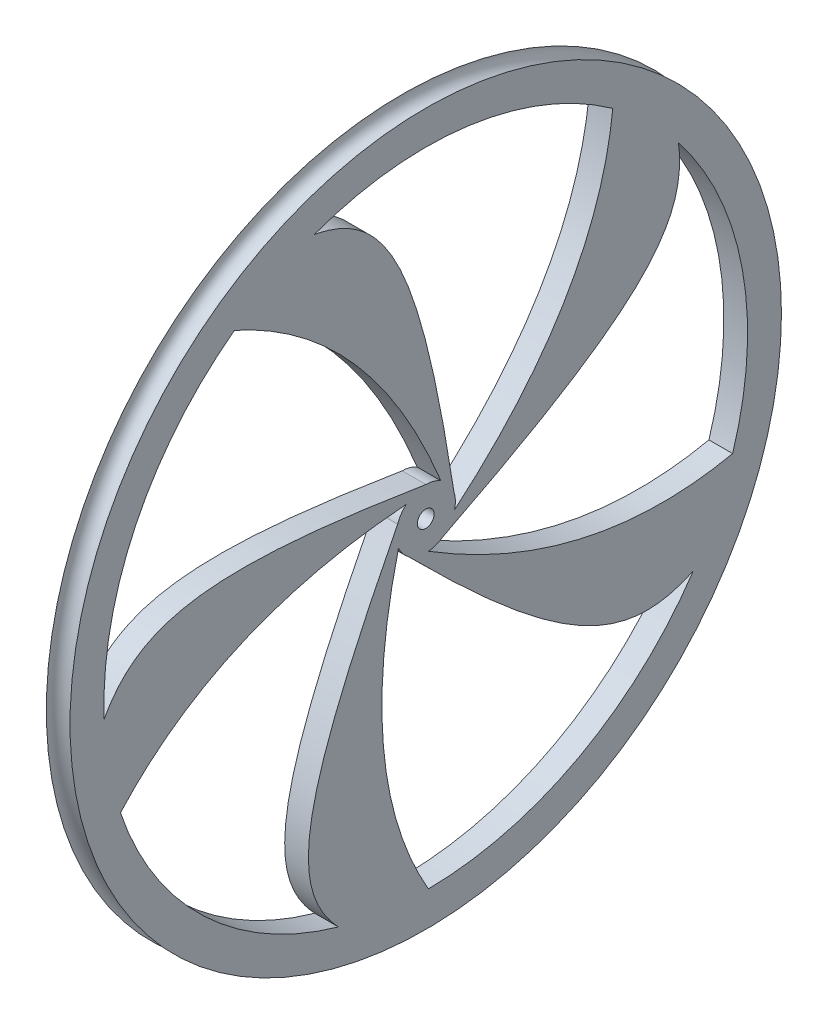
from build123d import *

# Parameters (mm, degrees)
SKETCH3_R           = 4.445
SKETCH3_R_2         = 1.2573
BOSS_EXTRUDE1_DEPTH = 1.778
BOSS_EXTRUDE2_DEPTH = 1.778
CIRPATTERN1_COUNT   = 5


with BuildPart() as part:
    # Sketch1 → Revolve1 (revolve)
    with BuildSketch(Plane.XY):
        with BuildLine():
            Line((-1.778, 48.26), (1.778, 48.26))
            Line((1.778, 48.26), (1.778, 53.34))
            ThreePointArc((1.778, 53.34), (0, 51.562), (-1.778, 53.34))
            Line((-1.778, 53.34), (-1.778, 48.26))
        make_face()
    revolve(axis=Axis((0, 0, 0), (-1, 0, 0)))



with BuildPart() as body_2:
    # Sketch3 → Boss-Extrude1 (new body, symmetric)
    with BuildSketch(Plane(origin=(0, 0, 0), x_dir=(0, 0, -1), z_dir=(1, 0, 0))):
        Circle(SKETCH3_R)
        Circle(SKETCH3_R_2, mode=Mode.SUBTRACT)
    extrude(amount=BOSS_EXTRUDE1_DEPTH, both=True)


with BuildPart() as part_1:
    add(part.part)

    add(body_2.part)  # Boss-Extrude2 merges body 2
    # Sketch4 → Boss-Extrude2 (add, symmetric)
    with BuildSketch(Plane(origin=(0, 0, 0), x_dir=(0, 0, -1), z_dir=(1, 0, 0))):
        with BuildLine():
            add(Edge.make_bspline(
                [(4.238371501, 1.339489461), (-0.797084769, 33.68038201), (-5.741030131, 43.234836537), (-16.711740024, 45.274113413)],
                knots=[0.007862153, 0.007862153, 0.007862153, 0.007862153, 0.582841342, 0.582841342, 0.582841342, 0.582841342], degree=3))
            ThreePointArc((-16.711740024, 45.274113413), (-22.926461421, 42.466515829), (-28.683393703, 38.810958835))
            add(Edge.make_bspline(
                [(2.269041799, 3.822234204), (-8.332097903, 29.7473311), (-28.683393703, 38.810958835)],
                knots=[0, 0, 0, 0.658247548, 0.658247548, 0.658247548], degree=2))
            ThreePointArc((2.269041799, 3.822234204), (3.482472158, 2.76232016), (4.238371501, 1.339489461))
        make_face()
    boss_extrude2 = extrude(amount=BOSS_EXTRUDE2_DEPTH, both=True)

    # CirPattern1: Boss-Extrude2 ×5 about axis
    cirpattern1_axis = Axis((0, 0, 0), (1, 0, 0))
    for i in range(1, CIRPATTERN1_COUNT):
        add(boss_extrude2.rotate(cirpattern1_axis, i * 360 / CIRPATTERN1_COUNT))


solid = part_1.part
